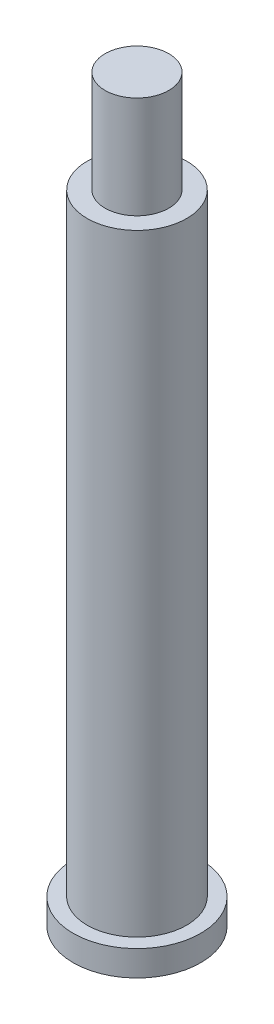
from build123d import *

# Parameters (mm, degrees)
SKETCH1_R           = 5
BOSS_EXTRUDE1_DEPTH = 2
SKETCH2_R           = 3.9
BOSS_EXTRUDE2_DEPTH = 48
SKETCH3_R           = 2.5
BOSS_EXTRUDE3_DEPTH = 8


with BuildPart() as part:
    # Sketch1 → Boss-Extrude1 (new body)
    with BuildSketch(Plane(origin=(0, 0, 0), x_dir=(1, 0, 0), z_dir=(0, 1, 0))):
        Circle(SKETCH1_R)
    extrude(amount=BOSS_EXTRUDE1_DEPTH)

    # Sketch2 → Boss-Extrude2 (add)
    with BuildSketch(Plane(origin=(0, 2, 0), x_dir=(1, 0, 0), z_dir=(0, 1, 0))):
        Circle(SKETCH2_R)
    extrude(amount=BOSS_EXTRUDE2_DEPTH)

    # Sketch3 → Boss-Extrude3 (add)
    with BuildSketch(Plane(origin=(0, 50, 0), x_dir=(1, 0, 0), z_dir=(0, 1, 0))):
        Circle(SKETCH3_R)
    extrude(amount=BOSS_EXTRUDE3_DEPTH)


solid = part.part
